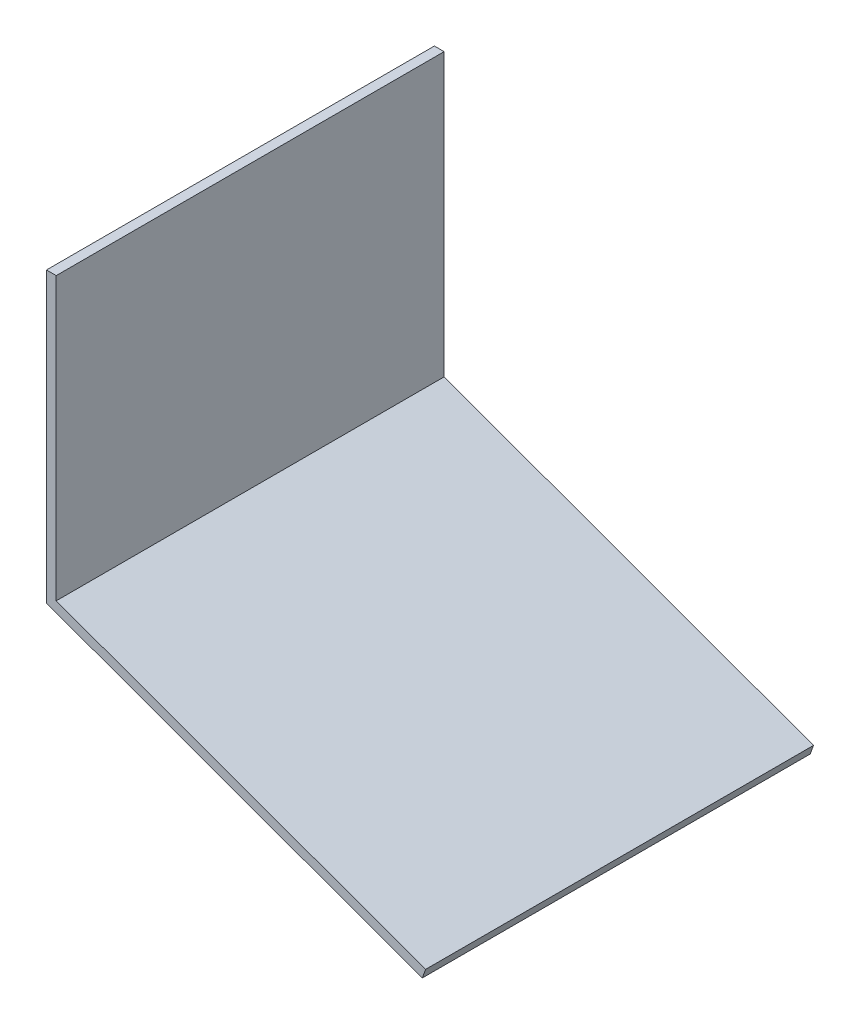
from build123d import *

# Parameters (mm, degrees)
BOSS_EXTRUDE1_START = 22
BOSS_EXTRUDE1_DEPTH = 199


with BuildPart() as part:
    # Sketch1 → Boss-Extrude1 (new body)
    with BuildSketch(Plane.XY.offset(BOSS_EXTRUDE1_START)):
        Polygon((-22, 30), (-22, -114.5), (167.5, -183.472359393), (165.789899283, -188.170822497), (-27, -118.001037691), (-27, 30), align=None)
    extrude(amount=-BOSS_EXTRUDE1_DEPTH)


solid = part.part
